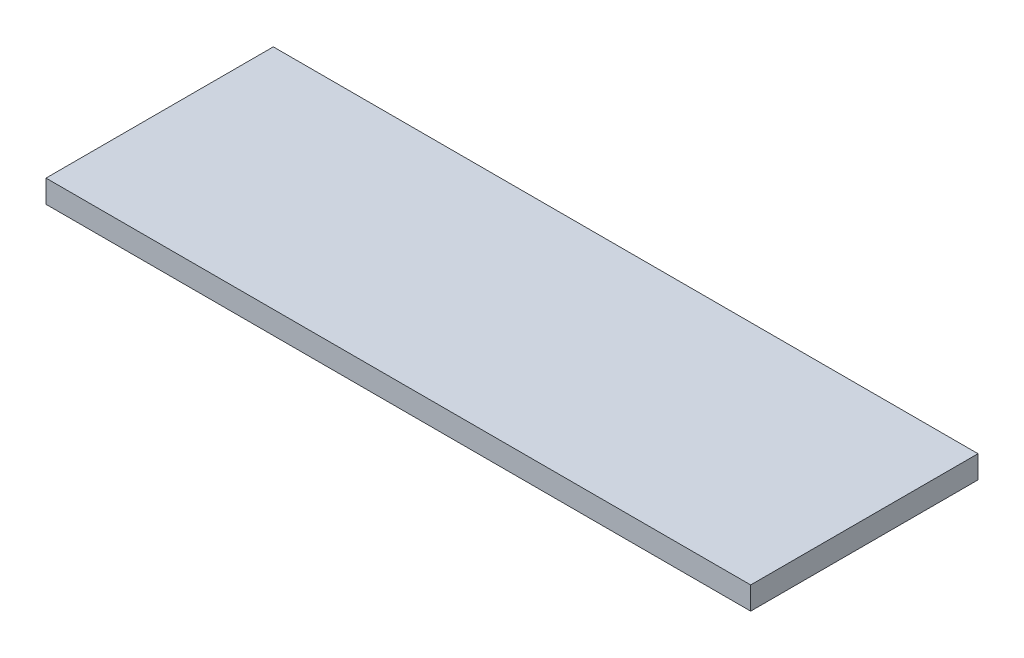
from build123d import *

# Parameters (mm, degrees)
SKETCH1_W           = 310
SKETCH1_H           = 100
BOSS_EXTRUDE1_DEPTH = 10


with BuildPart() as part:
    # Sketch1 → Boss-Extrude1 (new body)
    with BuildSketch(Plane(origin=(0, 0, 0), x_dir=(1, 0, 0), z_dir=(0, 1, 0))):
        Rectangle(SKETCH1_W, SKETCH1_H)
    extrude(amount=BOSS_EXTRUDE1_DEPTH)


solid = part.part
